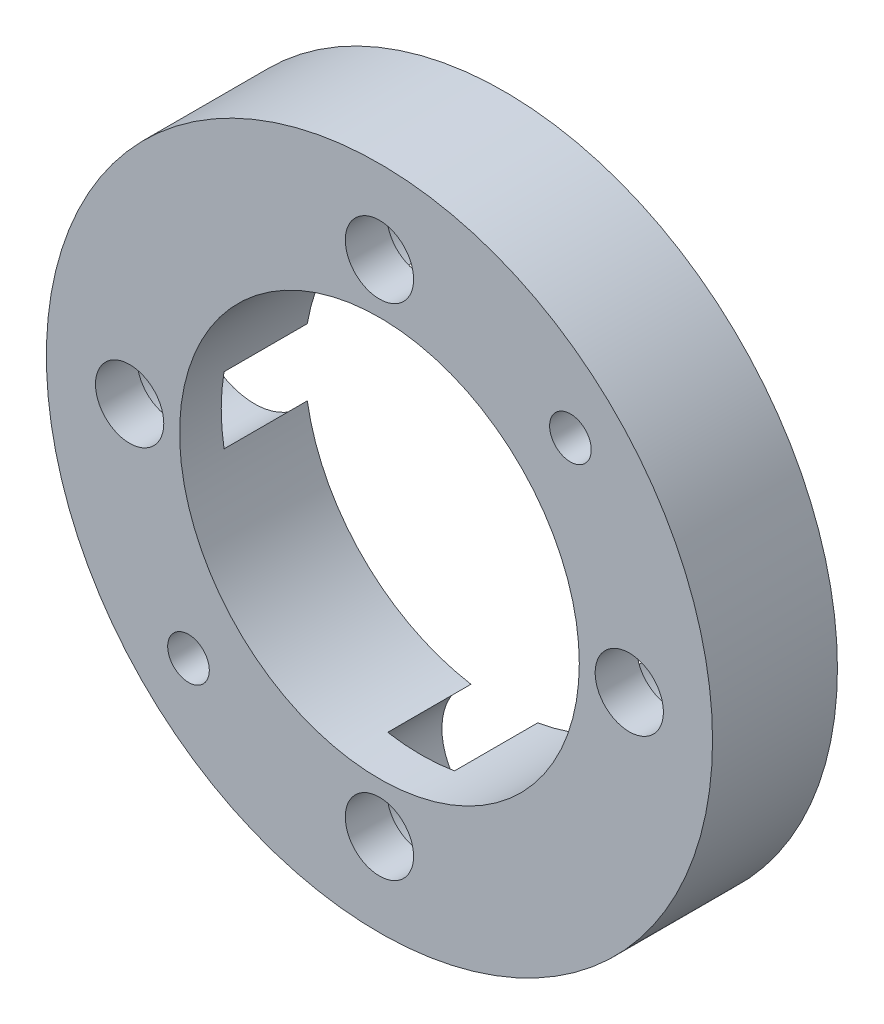
from build123d import *

# Parameters (mm, degrees)
SKETCH_1_R          = 20
SKETCH_1_R_2        = 2.05
EXTRUDE_1_DEPTH     = 7.5
SKETCH_2_R          = 1.25
SKETCH_2_R_2        = 12
CUT_EXTRUDE_1_DEPTH = 8.5
SKETCH_4_R          = 3.75
CUT_EXTRUDE_3_DEPTH = 5


with BuildPart() as part:
    # ｽｹｯﾁ1 → ﾎﾞｽ - 押し出し1 (new body)
    with BuildSketch(Plane.XY):
        Circle(SKETCH_1_R)
        with Locations((0, 15)):
            Circle(SKETCH_1_R_2, mode=Mode.SUBTRACT)
        with Locations((15, 0)):
            Circle(SKETCH_1_R_2, mode=Mode.SUBTRACT)
        with Locations((0, -15)):
            Circle(SKETCH_1_R_2, mode=Mode.SUBTRACT)
        with Locations((-15, 0)):
            Circle(SKETCH_1_R_2, mode=Mode.SUBTRACT)
    extrude(amount=EXTRUDE_1_DEPTH)

    # ｽｹｯﾁ2 → ｶｯﾄ - 押し出し1 (cut, through all)
    with BuildSketch(Plane.XY.offset(7.5)):
        with Locations((11.465736457, 11.465736457)):
            Circle(SKETCH_2_R)
        with Locations((-11.465736457, -11.465736457)):
            Circle(SKETCH_2_R)
        Circle(SKETCH_2_R_2)
    extrude(amount=-CUT_EXTRUDE_1_DEPTH, mode=Mode.SUBTRACT)

    # ｽｹｯﾁ4 → ｶｯﾄ - 押し出し3 (cut)
    with BuildSketch(Plane(origin=(0, 0, 0), x_dir=(-1, 0, 0), z_dir=(0, 0, -1))):
        with Locations((0, 15)):
            Circle(SKETCH_4_R)
        with Locations((15, 0)):
            Circle(SKETCH_4_R)
        with Locations((0, -15)):
            Circle(SKETCH_4_R)
        with Locations((-15, 0)):
            Circle(SKETCH_4_R)
    extrude(amount=-CUT_EXTRUDE_3_DEPTH, mode=Mode.SUBTRACT)


solid = part.part
